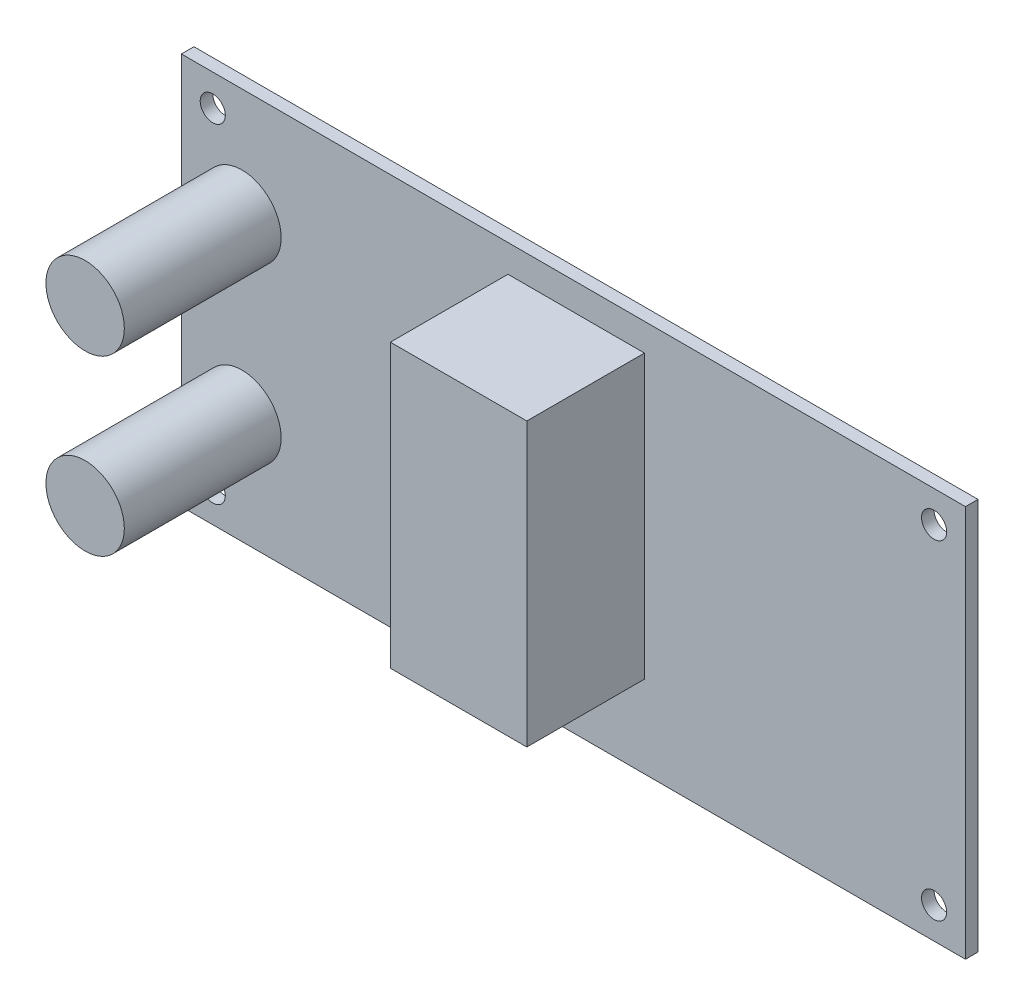
from build123d import *

# Parameters (mm, degrees)
ESQUISSE1_W        = 100
ESQUISSE1_H        = 50
ESQUISSE1_R        = 1.6
BOSS_EXTRU_1_DEPTH = 1.6
ESQUISSE2_R        = 5
BOSS_EXTRU_2_DEPTH = 20
ESQUISSE3_W        = 17.40280045
ESQUISSE3_H        = 36.018530138
BOSS_EXTRU_3_DEPTH = 15


with BuildPart() as part:
    # Esquisse1 → Boss.-Extru.1 (new body)
    with BuildSketch(Plane.XY):
        Rectangle(ESQUISSE1_W, ESQUISSE1_H)
        with Locations((-46, 21)):
            Circle(ESQUISSE1_R, mode=Mode.SUBTRACT)
        with Locations((46, 21)):
            Circle(ESQUISSE1_R, mode=Mode.SUBTRACT)
        with Locations((46, -21)):
            Circle(ESQUISSE1_R, mode=Mode.SUBTRACT)
        with Locations((-46, -21)):
            Circle(ESQUISSE1_R, mode=Mode.SUBTRACT)
    extrude(amount=BOSS_EXTRU_1_DEPTH)

    # Esquisse2 → Boss.-Extru.2 (add)
    with BuildSketch(Plane.XY.offset(1.6)):
        with Locations((-42.277991317, 11.052639899)):
            Circle(ESQUISSE2_R)
        with Locations((-42.277991317, -11.052639899)):
            Circle(ESQUISSE2_R)
    extrude(amount=BOSS_EXTRU_2_DEPTH)

    # Esquisse3 → Boss.-Extru.3 (add)
    with BuildSketch(Plane.XY.offset(1.6)):
        with Locations((0.355180215, 3.481690573)):
            Rectangle(ESQUISSE3_W, ESQUISSE3_H)
    extrude(amount=BOSS_EXTRU_3_DEPTH)


solid = part.part
